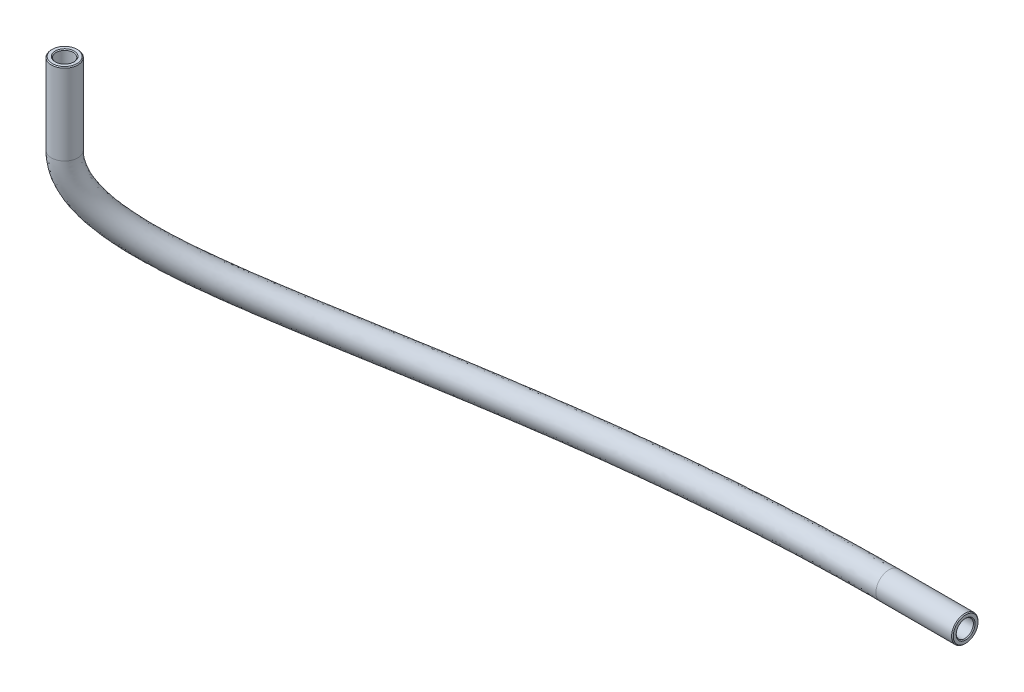
from build123d import *

# Parameters (mm, degrees)
SKETCH1_R     = 2
SKETCH1_R_2   = 1.3
CHAMFER1_SIZE = 0.127


with BuildPart() as part:
    # Sweep1: sweep along a curve in space
    with BuildLine() as sweep1_path:
        Line((146.325, -62.025, 13.85), (146.325, -74.325, 13.85))
        add(Edge.make_bspline(
            [(237.525, -102.482256564, -19.725), (204.493010201, -102.482256564, -19.725), (160.907942126, -96.189695695, -2.9375), (146.325, -82.015845318, 13.85), (146.325, -74.325, 13.85)],
            knots=[0, 0, 0, 0, 0.535743508, 1, 1, 1, 1], degree=3))
        Line((249.105, -102.482256564, -19.725), (237.525, -102.482256564, -19.725))
    # Sketch1 → Sweep1 (sweep)
    with BuildSketch(Plane.ZY.offset(-239.725)):
        with Locations((-19.725, -102.482256564)):
            Circle(SKETCH1_R)
        with Locations((-19.725, -102.482256564)):
            Circle(SKETCH1_R_2, mode=Mode.SUBTRACT)
    sweep(path=sweep1_path.line)

    # Chamfer1
    chamfer1_edges = [part.edges().sort_by_distance(p)[0] for p in [
        (249.105, -102.482256564, -21.025),
        (249.105, -102.482256564, -21.725),
        (145.598160645, -62.025, 12.772176011),
        (145.206785607, -62.025, 12.191809248),
    ]]
    chamfer(chamfer1_edges, length=CHAMFER1_SIZE)


solid = part.part
